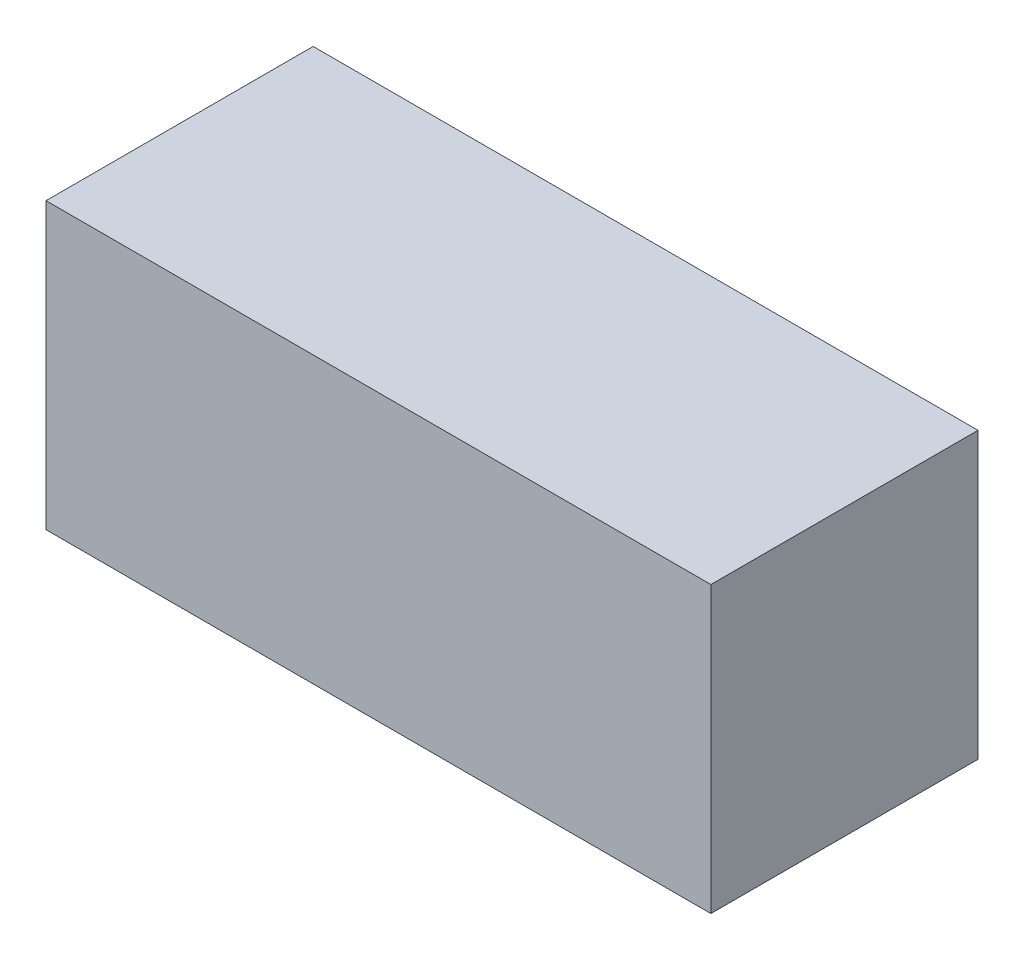
from build123d import *

# Parameters (mm, degrees)
SKETCH1_W           = 112
SKETCH1_H           = 45
BOSS_EXTRUDE1_DEPTH = 48


with BuildPart() as part:
    # Sketch1 → Boss-Extrude1 (new body)
    with BuildSketch(Plane(origin=(0, 0, 0), x_dir=(1, 0, 0), z_dir=(0, 1, 0))):
        Rectangle(SKETCH1_W, SKETCH1_H)
    extrude(amount=BOSS_EXTRUDE1_DEPTH)


solid = part.part
